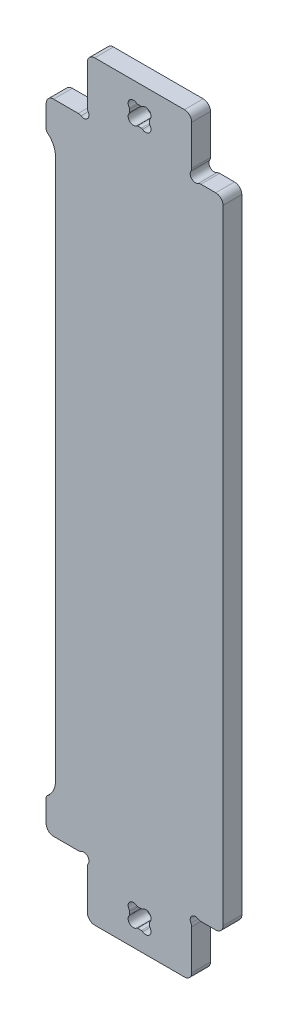
from build123d import *

# Parameters (mm, degrees)
BOSS_EXTRU_2_DEPTH      = 18
ENL_V_MAT_EXTRU_1_DEPTH = 19
CONG_1_R                = 7


with BuildPart() as part:
    # Esquisse2 → Boss.-Extru.2 (new body)
    with BuildSketch(Plane.XY):
        with BuildLine():
            Line((0, 0), (100, 0))
            Line((100, 0), (100, 45.254412261))
            ThreePointArc((100, 45.254412261), (99.813462099, 46.607402512), (99.267766953, 47.859439178))
            ThreePointArc((99.267766953, 47.859439178), (100, 54), (106.140560822, 54.732233047))
            ThreePointArc((106.140560822, 54.732233047), (107.392597488, 54.186537901), (108.745587739, 54))
            Line((108.745587739, 54), (130, 54))
            Line((130, 54), (130, 360))
            Line((130, 360), (-30.494949366, 360))
            Line((-30.494949366, 360), (-30.494949366, 101.23368794))
            ThreePointArc((-30.494949366, 101.23368794), (-32.612333247, 92.044193475), (-38.537502558, 84.707812102))
            ThreePointArc((-38.537502558, 84.707812102), (-39.242879856, 83.834433367), (-39.494949366, 82.740445931))
            Line((-39.494949366, 82.740445931), (-39.494949366, 54))
            Line((-39.494949366, 54), (-8.745587739, 54))
            ThreePointArc((-8.745587739, 54), (-7.392597488, 54.186537901), (-6.140560822, 54.732233047))
            ThreePointArc((-6.140560822, 54.732233047), (0, 54), (0.732233047, 47.859439178))
            ThreePointArc((0.732233047, 47.859439178), (0.186537901, 46.607402512), (0, 45.254412261))
            Line((0, 45.254412261), (0, 0))
        make_face()
    extrude(amount=BOSS_EXTRU_2_DEPTH)

    # Esquisse1 → Enlèv. mat.-Extru.1 (cut, through all)
    with BuildSketch(Plane.XY):
        with BuildLine():
            Line((59.5, 28.248771852), (59.5, 25.751228148))
            ThreePointArc((59.5, 25.751228148), (59.599672829, 25.160561143), (59.88765279, 24.635309084))
            ThreePointArc((59.88765279, 24.635309084), (59.5, 18), (52.864690916, 17.61234721))
            ThreePointArc((52.864690916, 17.61234721), (52.339438857, 17.900327171), (51.748771852, 18))
            Line((51.748771852, 18), (48.251228148, 18))
            ThreePointArc((48.251228148, 18), (47.660561143, 17.900327171), (47.135309084, 17.61234721))
            ThreePointArc((47.135309084, 17.61234721), (40.5, 18), (40.11234721, 24.635309084))
            ThreePointArc((40.11234721, 24.635309084), (40.400327171, 25.160561143), (40.5, 25.751228148))
            Line((40.5, 25.751228148), (40.5, 28.248771852))
            ThreePointArc((40.5, 28.248771852), (40.400327171, 28.839438857), (40.11234721, 29.364690916))
            ThreePointArc((40.11234721, 29.364690916), (40.5, 36), (47.135309084, 36.38765279))
            ThreePointArc((47.135309084, 36.38765279), (47.660561143, 36.099672829), (48.251228148, 36))
            Line((48.251228148, 36), (51.748771852, 36))
            ThreePointArc((51.748771852, 36), (52.339438857, 36.099672829), (52.864690916, 36.38765279))
            ThreePointArc((52.864690916, 36.38765279), (59.5, 36), (59.88765279, 29.364690916))
            ThreePointArc((59.88765279, 29.364690916), (59.599672829, 28.839438857), (59.5, 28.248771852))
        make_face()
    extrude(amount=ENL_V_MAT_EXTRU_1_DEPTH, mode=Mode.SUBTRACT)

    # Congé1
    cong_1_edges = [part.edges().sort_by_distance(p)[0] for p in [
        (-39.494949366, 54, 9),
        (130, 54, 9),
        (100, 0, 9),
        (0, 0, 9),
    ]]
    fillet(cong_1_edges, radius=CONG_1_R)

    # Symétrie1: part across plane


with BuildPart() as part_1:
    add(part.part)
    add(part.part.mirror(Plane(origin=(130, 360, 18), x_dir=(0, 0, 1), z_dir=(0, -1, 0))))


solid = part_1.part
